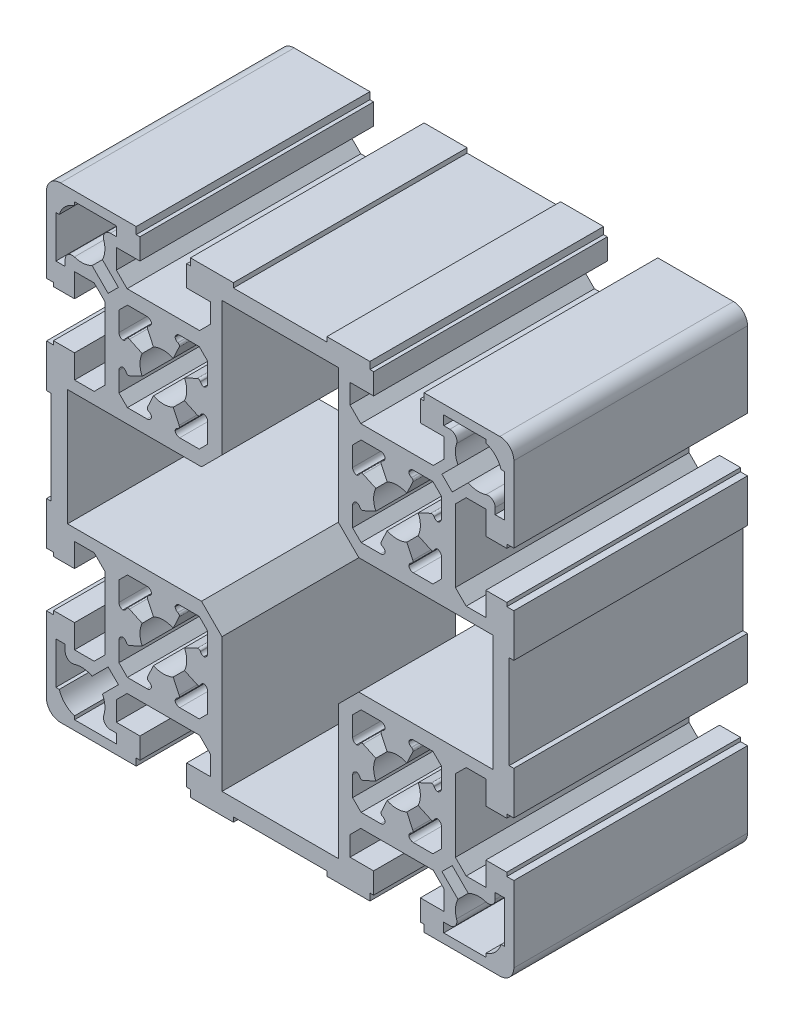
from build123d import *

# Parameters (mm, degrees)
BASE_EXTRUDE_DEPTH = 50


with BuildPart() as part:
    # Sketch1 → Base-Extrude (new body)
    with BuildSketch(Plane.XY):
        with BuildLine():
            Line((-17.25, -37.5), (-14.95, -39.8))
            Line((-14.95, -39.8), (-14.95, -44))
            Line((-14.95, -44), (-20, -44))
            Line((-20, -44), (-20, -48.5))
            Line((-20, -48.5), (-19.2, -48.5))
            Line((-19.2, -48.5), (-19.2, -50))
            Line((-19.2, -50), (-10, -50))
            Line((-10, -50), (-10, -49))
            Line((-10, -49), (10, -49))
            Line((10, -49), (10, -50))
            Line((10, -50), (19.2, -50))
            Line((19.2, -50), (19.2, -48.5))
            Line((19.2, -48.5), (20, -48.5))
            Line((20, -48.5), (20, -44))
            Line((20, -44), (14.95, -44))
            Line((14.95, -44), (14.95, -39.8))
            Line((14.95, -39.8), (17.25, -37.5))
            Line((17.25, -37.5), (32.75, -37.5))
            Line((32.75, -37.5), (35.05, -39.8))
            Line((35.05, -39.8), (35.05, -44))
            Line((35.05, -44), (30, -44))
            Line((30, -44), (30, -48.5))
            Line((30, -48.5), (30.8, -48.5))
            Line((30.8, -48.5), (30.8, -50))
            Line((30.8, -50), (47, -50))
            ThreePointArc((47, -50), (49.121320344, -49.121320344), (50, -47))
            Line((50, -47), (50, -30.8))
            Line((50, -30.8), (48.5, -30.8))
            Line((48.5, -30.8), (48.5, -30))
            Line((48.5, -30), (44, -30))
            Line((44, -30), (44, -35.05))
            Line((44, -35.05), (39.8, -35.05))
            Line((39.8, -35.05), (37.5, -32.75))
            Line((37.5, -32.75), (37.5, -17.25))
            Line((37.5, -17.25), (39.8, -14.95))
            Line((39.8, -14.95), (44, -14.95))
            Line((44, -14.95), (44, -20))
            Line((44, -20), (48.5, -20))
            Line((48.5, -20), (48.5, -19.2))
            Line((48.5, -19.2), (50, -19.2))
            Line((50, -19.2), (50, -10))
            Line((50, -10), (49, -10))
            Line((49, -10), (49, 10))
            Line((49, 10), (50, 10))
            Line((50, 10), (50, 19.2))
            Line((50, 19.2), (48.5, 19.2))
            Line((48.5, 19.2), (48.5, 20))
            Line((48.5, 20), (44, 20))
            Line((44, 20), (44, 14.95))
            Line((44, 14.95), (39.8, 14.95))
            Line((39.8, 14.95), (37.5, 17.25))
            Line((37.5, 17.25), (37.5, 32.75))
            Line((37.5, 32.75), (39.8, 35.05))
            Line((39.8, 35.05), (44, 35.05))
            Line((44, 35.05), (44, 30))
            Line((44, 30), (48.5, 30))
            Line((48.5, 30), (48.5, 30.8))
            Line((48.5, 30.8), (50, 30.8))
            Line((50, 30.8), (50, 47))
            ThreePointArc((50, 47), (49.121320344, 49.121320344), (47, 50))
            Line((47, 50), (30.8, 50))
            Line((30.8, 50), (30.8, 48.5))
            Line((30.8, 48.5), (30, 48.5))
            Line((30, 48.5), (30, 44))
            Line((30, 44), (35.05, 44))
            Line((35.05, 44), (35.05, 39.8))
            Line((35.05, 39.8), (32.75, 37.5))
            Line((32.75, 37.5), (17.25, 37.5))
            Line((17.25, 37.5), (14.95, 39.8))
            Line((14.95, 39.8), (14.95, 44))
            Line((14.95, 44), (20, 44))
            Line((20, 44), (20, 48.5))
            Line((20, 48.5), (19.2, 48.5))
            Line((19.2, 48.5), (19.2, 50))
            Line((19.2, 50), (10, 50))
            Line((10, 50), (10, 49))
            Line((10, 49), (-10, 49))
            Line((-10, 49), (-10, 50))
            Line((-10, 50), (-19.2, 50))
            Line((-19.2, 50), (-19.2, 48.5))
            Line((-19.2, 48.5), (-20, 48.5))
            Line((-20, 48.5), (-20, 44))
            Line((-20, 44), (-14.95, 44))
            Line((-14.95, 44), (-14.95, 39.8))
            Line((-14.95, 39.8), (-17.25, 37.5))
            Line((-17.25, 37.5), (-32.75, 37.5))
            Line((-32.75, 37.5), (-35.05, 39.8))
            Line((-35.05, 39.8), (-35.05, 44))
            Line((-35.05, 44), (-30, 44))
            Line((-30, 44), (-30, 48.5))
            Line((-30, 48.5), (-30.8, 48.5))
            Line((-30.8, 48.5), (-30.8, 50))
            Line((-30.8, 50), (-47, 50))
            ThreePointArc((-47, 50), (-49.121320344, 49.121320344), (-50, 47))
            Line((-50, 47), (-50, 30.8))
            Line((-50, 30.8), (-48.5, 30.8))
            Line((-48.5, 30.8), (-48.5, 30))
            Line((-48.5, 30), (-44, 30))
            Line((-44, 30), (-44, 35.05))
            Line((-44, 35.05), (-39.8, 35.05))
            Line((-39.8, 35.05), (-37.5, 32.75))
            Line((-37.5, 32.75), (-37.5, 17.25))
            Line((-37.5, 17.25), (-39.8, 14.95))
            Line((-39.8, 14.95), (-44, 14.95))
            Line((-44, 14.95), (-44, 20))
            Line((-44, 20), (-48.5, 20))
            Line((-48.5, 20), (-48.5, 19.2))
            Line((-48.5, 19.2), (-50, 19.2))
            Line((-50, 19.2), (-50, 10))
            Line((-50, 10), (-49, 10))
            Line((-49, 10), (-49, -10))
            Line((-49, -10), (-50, -10))
            Line((-50, -10), (-50, -19.2))
            Line((-50, -19.2), (-48.5, -19.2))
            Line((-48.5, -19.2), (-48.5, -20))
            Line((-48.5, -20), (-44, -20))
            Line((-44, -20), (-44, -14.95))
            Line((-44, -14.95), (-39.8, -14.95))
            Line((-39.8, -14.95), (-37.5, -17.25))
            Line((-37.5, -17.25), (-37.5, -32.75))
            Line((-37.5, -32.75), (-39.8, -35.05))
            Line((-39.8, -35.05), (-44, -35.05))
            Line((-44, -35.05), (-44, -30))
            Line((-44, -30), (-48.5, -30))
            Line((-48.5, -30), (-48.5, -30.8))
            Line((-48.5, -30.8), (-50, -30.8))
            Line((-50, -30.8), (-50, -47))
            ThreePointArc((-50, -47), (-49.121320344, -49.121320344), (-47, -50))
            Line((-47, -50), (-30.8, -50))
            Line((-30.8, -50), (-30.8, -48.5))
            Line((-30.8, -48.5), (-30, -48.5))
            Line((-30, -48.5), (-30, -44))
            Line((-30, -44), (-35.05, -44))
            Line((-35.05, -44), (-35.05, -39.8))
            Line((-35.05, -39.8), (-32.75, -37.5))
            Line((-32.75, -37.5), (-17.25, -37.5))
        make_face()
        with BuildLine():
            Line((-15.501428488, -32.680320318), (-17.320519374, -34.499411204))
            Line((-17.320519374, -34.499411204), (-21.501428488, -34.499411204))
            ThreePointArc((-21.501428488, -34.499411204), (-22.143687504, -34.265898879), (-22.485995728, -33.674417917))
            ThreePointArc((-22.485995728, -33.674417917), (-22.294361697, -33.240116066), (-21.92404675, -32.943116843))
            Line((-21.92404675, -32.943116843), (-21.862327157, -32.914336524))
            ThreePointArc((-21.862327157, -32.914336524), (-21.603789977, -32.632192702), (-21.620482394, -32.2498735))
            Line((-21.620482394, -32.2498735), (-22.888337179, -29.530950139))
            ThreePointArc((-22.888337179, -29.530950139), (-25.001428488, -29.999411204), (-27.114519797, -29.530950139))
            Line((-27.114519797, -29.530950139), (-28.382374582, -32.2498735))
            ThreePointArc((-28.382374582, -32.2498735), (-28.399066999, -32.632192702), (-28.140529819, -32.914336524))
            Line((-28.140529819, -32.914336524), (-28.078810226, -32.943116843))
            ThreePointArc((-28.078810226, -32.943116843), (-27.708495279, -33.240116066), (-27.516861248, -33.674417917))
            ThreePointArc((-27.516861248, -33.674417917), (-27.859169472, -34.265898879), (-28.501428488, -34.499411204))
            Line((-28.501428488, -34.499411204), (-32.682337602, -34.499411204))
            Line((-32.682337602, -34.499411204), (-34.501428488, -32.680320318))
            Line((-34.501428488, -32.680320318), (-34.501428488, -28.499411204))
            ThreePointArc((-34.501428488, -28.499411204), (-34.267916164, -27.857152188), (-33.676435201, -27.514843963))
            ThreePointArc((-33.676435201, -27.514843963), (-33.242133351, -27.706477994), (-32.945134128, -28.076792942))
            Line((-32.945134128, -28.076792942), (-32.916353809, -28.138512535))
            ThreePointArc((-32.916353809, -28.138512535), (-32.634209987, -28.397049714), (-32.251890784, -28.380357297))
            Line((-32.251890784, -28.380357297), (-29.532967423, -27.112502512))
            ThreePointArc((-29.532967423, -27.112502512), (-30.001428488, -24.999411204), (-29.532967423, -22.886319895))
            Line((-29.532967423, -22.886319895), (-32.251890784, -21.61846511))
            ThreePointArc((-32.251890784, -21.61846511), (-32.634209987, -21.601772693), (-32.916353809, -21.860309872))
            Line((-32.916353809, -21.860309872), (-32.94370564, -21.922618262))
            ThreePointArc((-32.94370564, -21.922618262), (-33.240704863, -22.292933209), (-33.675006713, -22.48456724))
            ThreePointArc((-33.675006713, -22.48456724), (-34.266487675, -22.142259016), (-34.5, -21.5))
            Line((-34.5, -21.5), (-34.5, -17.319090886))
            Line((-34.5, -17.319090886), (-32.680909114, -15.5))
            Line((-32.680909114, -15.5), (-28.5, -15.5))
            ThreePointArc((-28.5, -15.5), (-27.857740984, -15.733512325), (-27.51543276, -16.324993287))
            ThreePointArc((-27.51543276, -16.324993287), (-27.707066791, -16.759295137), (-28.077381738, -17.05629436))
            Line((-28.077381738, -17.05629436), (-28.139101331, -17.085074679))
            ThreePointArc((-28.139101331, -17.085074679), (-28.397638511, -17.367218501), (-28.380946094, -17.749537704))
            Line((-28.380946094, -17.749537704), (-27.113571921, -20.467430387))
            ThreePointArc((-27.113571921, -20.467430387), (-25.000905581, -19.999411231), (-22.888337179, -20.467872268))
            Line((-22.888337179, -20.467872268), (-21.620482394, -17.748948907))
            ThreePointArc((-21.620482394, -17.748948907), (-21.603789977, -17.366629705), (-21.862327157, -17.084485883))
            Line((-21.862327157, -17.084485883), (-21.92404675, -17.055705564))
            ThreePointArc((-21.92404675, -17.055705564), (-22.294361697, -16.758706341), (-22.485995728, -16.32440449))
            ThreePointArc((-22.485995728, -16.32440449), (-22.143687504, -15.732923528), (-21.501428488, -15.499411204))
            Line((-21.501428488, -15.499411204), (-17.320519374, -15.499411204))
            Line((-17.320519374, -15.499411204), (-15.501428488, -17.318502089))
            Line((-15.501428488, -17.318502089), (-15.501428488, -21.499411204))
            ThreePointArc((-15.501428488, -21.499411204), (-15.734940813, -22.141670219), (-16.326421775, -22.483978444))
            ThreePointArc((-16.326421775, -22.483978444), (-16.760723625, -22.292344413), (-17.057722849, -21.922029465))
            Line((-17.057722849, -21.922029465), (-17.086503167, -21.860309872))
            ThreePointArc((-17.086503167, -21.860309872), (-17.368646989, -21.601772693), (-17.750966192, -21.61846511))
            Line((-17.750966192, -21.61846511), (-20.469889553, -22.886319895))
            ThreePointArc((-20.469889553, -22.886319895), (-20.001428488, -24.999411204), (-20.469889553, -27.112502512))
            Line((-20.469889553, -27.112502512), (-17.750966192, -28.380357297))
            ThreePointArc((-17.750966192, -28.380357297), (-17.368646989, -28.397049714), (-17.086503167, -28.138512535))
            Line((-17.086503167, -28.138512535), (-17.057722849, -28.076792942))
            ThreePointArc((-17.057722849, -28.076792942), (-16.760723625, -27.706477994), (-16.326421775, -27.514843963))
            ThreePointArc((-16.326421775, -27.514843963), (-15.734940813, -27.857152188), (-15.501428488, -28.499411204))
            Line((-15.501428488, -28.499411204), (-15.501428488, -32.680320318))
        make_face(mode=Mode.SUBTRACT)
        Polygon((-12.45, -16.83355698), (-16.83355698, -12.45), (-45.5, -12.45), (-45.5, 12.45), (-16.83355698, 12.45), (-12.45, 16.83355698), (-12.45, 45.5), (12.45, 45.5), (12.45, 16.83355698), (16.83355698, 12.45), (45.5, 12.45), (45.5, -12.45), (16.83355698, -12.45), (12.45, -16.83355698), (12.45, -45.5), (-12.45, -45.5), align=None, mode=Mode.SUBTRACT)
        with BuildLine():
            Line((-48, -44), (-48, -35))
            Line((-48, -35), (-46, -35))
            Line((-46, -35), (-46, -36.315341562))
            ThreePointArc((-46, -36.315341562), (-45.382522608, -37.528252872), (-44.038461538, -37.742570432))
            ThreePointArc((-44.038461538, -37.742570432), (-42.111403126, -37.515123625), (-40.242871851, -38.038456263))
            Line((-40.242871851, -38.038456263), (-36.813982694, -34.609567107))
            Line((-36.813982694, -34.609567107), (-34.609567107, -36.813982694))
            Line((-34.609567107, -36.813982694), (-38.038456263, -40.242871851))
            ThreePointArc((-38.038456263, -40.242871851), (-37.515123625, -42.111403126), (-37.742570432, -44.038461538))
            ThreePointArc((-37.742570432, -44.038461538), (-37.528252872, -45.382522608), (-36.315341562, -46))
            Line((-36.315341562, -46), (-35, -46))
            Line((-35, -46), (-35, -48))
            Line((-35, -48), (-44, -48))
            Line((-44, -48), (-44, -47.269696007))
            ThreePointArc((-44, -47.269696007), (-46.035533906, -46.035533906), (-47.269696007, -44))
            Line((-47.269696007, -44), (-48, -44))
        make_face(mode=Mode.SUBTRACT)
        with BuildLine():
            Line((48, -35), (48, -44))
            Line((48, -44), (47.269696007, -44))
            ThreePointArc((47.269696007, -44), (46.035533906, -46.035533906), (44, -47.269696007))
            Line((44, -47.269696007), (44, -48))
            Line((44, -48), (35, -48))
            Line((35, -48), (35, -46))
            Line((35, -46), (36.315341562, -46))
            ThreePointArc((36.315341562, -46), (37.528252872, -45.382522608), (37.742570432, -44.038461538))
            ThreePointArc((37.742570432, -44.038461538), (37.515123625, -42.111403126), (38.038456263, -40.242871851))
            Line((38.038456263, -40.242871851), (34.609567107, -36.813982694))
            Line((34.609567107, -36.813982694), (36.813982694, -34.609567107))
            Line((36.813982694, -34.609567107), (40.242871851, -38.038456263))
            ThreePointArc((40.242871851, -38.038456263), (42.111403126, -37.515123625), (44.038461538, -37.742570432))
            ThreePointArc((44.038461538, -37.742570432), (45.382522608, -37.528252872), (46, -36.315341562))
            Line((46, -36.315341562), (46, -35))
            Line((46, -35), (48, -35))
        make_face(mode=Mode.SUBTRACT)
        with BuildLine():
            Line((34.5, -17.319090886), (34.5, -21.5))
            ThreePointArc((34.5, -21.5), (34.266487675, -22.142259016), (33.675006713, -22.48456724))
            ThreePointArc((33.675006713, -22.48456724), (33.240704863, -22.292933209), (32.94370564, -21.922618262))
            Line((32.94370564, -21.922618262), (32.914925321, -21.860898669))
            ThreePointArc((32.914925321, -21.860898669), (32.632781499, -21.602361489), (32.250462296, -21.619053906))
            Line((32.250462296, -21.619053906), (29.531538935, -22.886908691))
            ThreePointArc((29.531538935, -22.886908691), (30, -25), (29.531538935, -27.113091309))
            Line((29.531538935, -27.113091309), (32.250462296, -28.380946094))
            ThreePointArc((32.250462296, -28.380946094), (32.632781499, -28.397638511), (32.914925321, -28.139101331))
            Line((32.914925321, -28.139101331), (32.94370564, -28.077381738))
            ThreePointArc((32.94370564, -28.077381738), (33.240704863, -27.707066791), (33.675006713, -27.51543276))
            ThreePointArc((33.675006713, -27.51543276), (34.266487675, -27.857740984), (34.5, -28.5))
            Line((34.5, -28.5), (34.5, -32.680909114))
            Line((34.5, -32.680909114), (32.680909114, -34.5))
            Line((32.680909114, -34.5), (28.5, -34.5))
            ThreePointArc((28.5, -34.5), (27.857740984, -34.266487675), (27.51543276, -33.675006713))
            ThreePointArc((27.51543276, -33.675006713), (27.707066791, -33.240704863), (28.077381738, -32.94370564))
            Line((28.077381738, -32.94370564), (28.139101331, -32.914925321))
            ThreePointArc((28.139101331, -32.914925321), (28.397638511, -32.632781499), (28.380946094, -32.250462296))
            Line((28.380946094, -32.250462296), (27.113091309, -29.531538935))
            ThreePointArc((27.113091309, -29.531538935), (25, -30), (22.886908691, -29.531538935))
            Line((22.886908691, -29.531538935), (21.619053906, -32.250462296))
            ThreePointArc((21.619053906, -32.250462296), (21.602361489, -32.632781499), (21.860898669, -32.914925321))
            Line((21.860898669, -32.914925321), (21.922618262, -32.94370564))
            ThreePointArc((21.922618262, -32.94370564), (22.292933209, -33.240704863), (22.48456724, -33.675006713))
            ThreePointArc((22.48456724, -33.675006713), (22.142259016, -34.266487675), (21.5, -34.5))
            Line((21.5, -34.5), (17.319090886, -34.5))
            Line((17.319090886, -34.5), (15.5, -32.680909114))
            Line((15.5, -32.680909114), (15.5, -28.5))
            ThreePointArc((15.5, -28.5), (15.733512325, -27.857740984), (16.324993287, -27.51543276))
            ThreePointArc((16.324993287, -27.51543276), (16.759295137, -27.707066791), (17.05629436, -28.077381738))
            Line((17.05629436, -28.077381738), (17.085074679, -28.139101331))
            ThreePointArc((17.085074679, -28.139101331), (17.367218501, -28.397638511), (17.749537704, -28.380946094))
            Line((17.749537704, -28.380946094), (20.468461065, -27.113091309))
            ThreePointArc((20.468461065, -27.113091309), (20, -25), (20.468461065, -22.886908691))
            Line((20.468461065, -22.886908691), (17.749537704, -21.619053906))
            ThreePointArc((17.749537704, -21.619053906), (17.367218501, -21.602361489), (17.085074679, -21.860898669))
            Line((17.085074679, -21.860898669), (17.05629436, -21.922618262))
            ThreePointArc((17.05629436, -21.922618262), (16.759295137, -22.292933209), (16.324993287, -22.48456724))
            ThreePointArc((16.324993287, -22.48456724), (15.733512325, -22.142259016), (15.5, -21.5))
            Line((15.5, -21.5), (15.5, -17.319090886))
            Line((15.5, -17.319090886), (17.319090886, -15.5))
            Line((17.319090886, -15.5), (21.5, -15.5))
            ThreePointArc((21.5, -15.5), (22.142259016, -15.733512325), (22.48456724, -16.324993287))
            ThreePointArc((22.48456724, -16.324993287), (22.292933209, -16.759295137), (21.922618262, -17.05629436))
            Line((21.922618262, -17.05629436), (21.860898669, -17.085074679))
            ThreePointArc((21.860898669, -17.085074679), (21.602361489, -17.367218501), (21.619053906, -17.749537704))
            Line((21.619053906, -17.749537704), (22.886908691, -20.468461065))
            ThreePointArc((22.886908691, -20.468461065), (25, -20), (27.113091309, -20.468461065))
            Line((27.113091309, -20.468461065), (28.380946094, -17.749537704))
            ThreePointArc((28.380946094, -17.749537704), (28.397638511, -17.367218501), (28.139101331, -17.085074679))
            Line((28.139101331, -17.085074679), (28.077381738, -17.05629436))
            ThreePointArc((28.077381738, -17.05629436), (27.707066791, -16.759295137), (27.51543276, -16.324993287))
            ThreePointArc((27.51543276, -16.324993287), (27.857740984, -15.733512325), (28.5, -15.5))
            Line((28.5, -15.5), (32.680909114, -15.5))
            Line((32.680909114, -15.5), (34.5, -17.319090886))
        make_face(mode=Mode.SUBTRACT)
        with BuildLine():
            Line((-17.319090886, 34.5), (-15.5, 32.680909114))
            Line((-15.5, 32.680909114), (-15.5, 28.5))
            ThreePointArc((-15.5, 28.5), (-15.733512325, 27.857740984), (-16.324993287, 27.51543276))
            ThreePointArc((-16.324993287, 27.51543276), (-16.759295137, 27.707066791), (-17.05629436, 28.077381738))
            Line((-17.05629436, 28.077381738), (-17.085074679, 28.139101331))
            ThreePointArc((-17.085074679, 28.139101331), (-17.367218501, 28.397638511), (-17.749537704, 28.380946094))
            Line((-17.749537704, 28.380946094), (-20.468461065, 27.113091309))
            ThreePointArc((-20.468461065, 27.113091309), (-20, 25), (-20.468461065, 22.886908691))
            Line((-20.468461065, 22.886908691), (-17.749537704, 21.619053906))
            ThreePointArc((-17.749537704, 21.619053906), (-17.367218501, 21.602361489), (-17.085074679, 21.860898669))
            Line((-17.085074679, 21.860898669), (-17.05629436, 21.922618262))
            ThreePointArc((-17.05629436, 21.922618262), (-16.759295137, 22.292933209), (-16.324993287, 22.48456724))
            ThreePointArc((-16.324993287, 22.48456724), (-15.733512325, 22.142259016), (-15.5, 21.5))
            Line((-15.5, 21.5), (-15.5, 17.319090886))
            Line((-15.5, 17.319090886), (-17.319090886, 15.5))
            Line((-17.319090886, 15.5), (-21.5, 15.5))
            ThreePointArc((-21.5, 15.5), (-22.142259016, 15.733512325), (-22.48456724, 16.324993287))
            ThreePointArc((-22.48456724, 16.324993287), (-22.292933209, 16.759295137), (-21.922618262, 17.05629436))
            Line((-21.922618262, 17.05629436), (-21.860898669, 17.085074679))
            ThreePointArc((-21.860898669, 17.085074679), (-21.602361489, 17.367218501), (-21.619053906, 17.749537704))
            Line((-21.619053906, 17.749537704), (-22.886908691, 20.468461065))
            ThreePointArc((-22.886908691, 20.468461065), (-25, 20), (-27.113091309, 20.468461065))
            Line((-27.113091309, 20.468461065), (-28.380946094, 17.749537704))
            ThreePointArc((-28.380946094, 17.749537704), (-28.397638511, 17.367218501), (-28.139101331, 17.085074679))
            Line((-28.139101331, 17.085074679), (-28.077381738, 17.05629436))
            ThreePointArc((-28.077381738, 17.05629436), (-27.707066791, 16.759295137), (-27.51543276, 16.324993287))
            ThreePointArc((-27.51543276, 16.324993287), (-27.857740984, 15.733512325), (-28.5, 15.5))
            Line((-28.5, 15.5), (-32.680909114, 15.5))
            Line((-32.680909114, 15.5), (-34.5, 17.319090886))
            Line((-34.5, 17.319090886), (-34.5, 21.5))
            ThreePointArc((-34.5, 21.5), (-34.266487675, 22.142259016), (-33.675006713, 22.48456724))
            ThreePointArc((-33.675006713, 22.48456724), (-33.240704863, 22.292933209), (-32.94370564, 21.922618262))
            Line((-32.94370564, 21.922618262), (-32.914925321, 21.860898669))
            ThreePointArc((-32.914925321, 21.860898669), (-32.632781499, 21.602361489), (-32.250462296, 21.619053906))
            Line((-32.250462296, 21.619053906), (-29.531538935, 22.886908691))
            ThreePointArc((-29.531538935, 22.886908691), (-30, 25), (-29.531538935, 27.113091309))
            Line((-29.531538935, 27.113091309), (-32.250462296, 28.380946094))
            ThreePointArc((-32.250462296, 28.380946094), (-32.632781499, 28.397638511), (-32.914925321, 28.139101331))
            Line((-32.914925321, 28.139101331), (-32.94370564, 28.077381738))
            ThreePointArc((-32.94370564, 28.077381738), (-33.240704863, 27.707066791), (-33.675006713, 27.51543276))
            ThreePointArc((-33.675006713, 27.51543276), (-34.266487675, 27.857740984), (-34.5, 28.5))
            Line((-34.5, 28.5), (-34.5, 32.680909114))
            Line((-34.5, 32.680909114), (-32.680909114, 34.5))
            Line((-32.680909114, 34.5), (-28.5, 34.5))
            ThreePointArc((-28.5, 34.5), (-27.857740984, 34.266487675), (-27.51543276, 33.675006713))
            ThreePointArc((-27.51543276, 33.675006713), (-27.707066791, 33.240704863), (-28.077381738, 32.94370564))
            Line((-28.077381738, 32.94370564), (-28.139690128, 32.916353809))
            ThreePointArc((-28.139690128, 32.916353809), (-28.398227307, 32.634209987), (-28.38153489, 32.251890784))
            Line((-28.38153489, 32.251890784), (-27.1130278, 29.531568549))
            ThreePointArc((-27.1130278, 29.531568549), (-24.999964963, 30), (-22.886908691, 29.531538935))
            Line((-22.886908691, 29.531538935), (-21.619053906, 32.250462296))
            ThreePointArc((-21.619053906, 32.250462296), (-21.602361489, 32.632781499), (-21.860898669, 32.914925321))
            Line((-21.860898669, 32.914925321), (-21.922618262, 32.94370564))
            ThreePointArc((-21.922618262, 32.94370564), (-22.292933209, 33.240704863), (-22.48456724, 33.675006713))
            ThreePointArc((-22.48456724, 33.675006713), (-22.142259016, 34.266487675), (-21.5, 34.5))
            Line((-21.5, 34.5), (-17.319090886, 34.5))
        make_face(mode=Mode.SUBTRACT)
        with BuildLine():
            Line((-48, 35), (-48, 44))
            Line((-48, 44), (-47.269696007, 44))
            ThreePointArc((-47.269696007, 44), (-46.035533906, 46.035533906), (-44, 47.269696007))
            Line((-44, 47.269696007), (-44, 48))
            Line((-44, 48), (-35, 48))
            Line((-35, 48), (-35, 46))
            Line((-35, 46), (-36.315341562, 46))
            ThreePointArc((-36.315341562, 46), (-37.528252872, 45.382522608), (-37.742570432, 44.038461538))
            ThreePointArc((-37.742570432, 44.038461538), (-37.515123625, 42.111403126), (-38.038456263, 40.242871851))
            Line((-38.038456263, 40.242871851), (-34.609567107, 36.813982694))
            Line((-34.609567107, 36.813982694), (-36.813982694, 34.609567107))
            Line((-36.813982694, 34.609567107), (-40.242871851, 38.038456263))
            ThreePointArc((-40.242871851, 38.038456263), (-42.111403126, 37.515123625), (-44.038461538, 37.742570432))
            ThreePointArc((-44.038461538, 37.742570432), (-45.382522608, 37.528252872), (-46, 36.315341562))
            Line((-46, 36.315341562), (-46, 35))
            Line((-46, 35), (-48, 35))
        make_face(mode=Mode.SUBTRACT)
        with BuildLine():
            Line((28.380946094, 17.749537704), (27.113091309, 20.468461065))
            ThreePointArc((27.113091309, 20.468461065), (25, 20), (22.886908691, 20.468461065))
            Line((22.886908691, 20.468461065), (21.619053906, 17.749537704))
            ThreePointArc((21.619053906, 17.749537704), (21.602361489, 17.367218501), (21.860898669, 17.085074679))
            Line((21.860898669, 17.085074679), (21.922618262, 17.05629436))
            ThreePointArc((21.922618262, 17.05629436), (22.292933209, 16.759295137), (22.48456724, 16.324993287))
            ThreePointArc((22.48456724, 16.324993287), (22.142259016, 15.733512325), (21.5, 15.5))
            Line((21.5, 15.5), (17.319090886, 15.5))
            Line((17.319090886, 15.5), (15.5, 17.319090886))
            Line((15.5, 17.319090886), (15.5, 21.5))
            ThreePointArc((15.5, 21.5), (15.733512325, 22.142259016), (16.324993287, 22.48456724))
            ThreePointArc((16.324993287, 22.48456724), (16.759295137, 22.292933209), (17.05629436, 21.922618262))
            Line((17.05629436, 21.922618262), (17.085074679, 21.860898669))
            ThreePointArc((17.085074679, 21.860898669), (17.367218501, 21.602361489), (17.749537704, 21.619053906))
            Line((17.749537704, 21.619053906), (20.468461065, 22.886908691))
            ThreePointArc((20.468461065, 22.886908691), (20, 25), (20.468461065, 27.113091309))
            Line((20.468461065, 27.113091309), (17.749537704, 28.380946094))
            ThreePointArc((17.749537704, 28.380946094), (17.367218501, 28.397638511), (17.085074679, 28.139101331))
            Line((17.085074679, 28.139101331), (17.05629436, 28.077381738))
            ThreePointArc((17.05629436, 28.077381738), (16.759295137, 27.707066791), (16.324993287, 27.51543276))
            ThreePointArc((16.324993287, 27.51543276), (15.733512325, 27.857740984), (15.5, 28.5))
            Line((15.5, 28.5), (15.5, 32.680909114))
            Line((15.5, 32.680909114), (17.319090886, 34.5))
            Line((17.319090886, 34.5), (21.5, 34.5))
            ThreePointArc((21.5, 34.5), (22.142259016, 34.266487675), (22.48456724, 33.675006713))
            ThreePointArc((22.48456724, 33.675006713), (22.292933209, 33.240704863), (21.922618262, 32.94370564))
            Line((21.922618262, 32.94370564), (21.860309872, 32.916353809))
            ThreePointArc((21.860309872, 32.916353809), (21.601772693, 32.634209987), (21.61846511, 32.251890784))
            Line((21.61846511, 32.251890784), (22.8869722, 29.531568549))
            ThreePointArc((22.8869722, 29.531568549), (25.000035037, 30), (27.113091309, 29.531538935))
            Line((27.113091309, 29.531538935), (28.380946094, 32.250462296))
            ThreePointArc((28.380946094, 32.250462296), (28.397638511, 32.632781499), (28.139101331, 32.914925321))
            Line((28.139101331, 32.914925321), (28.076792942, 32.942277151))
            ThreePointArc((28.076792942, 32.942277151), (27.706477994, 33.239276375), (27.514843963, 33.673578225))
            ThreePointArc((27.514843963, 33.673578225), (27.857152188, 34.265059187), (28.499411203, 34.498571512))
            Line((28.499411203, 34.498571512), (32.680320318, 34.498571512))
            Line((32.680320318, 34.498571512), (34.499411203, 32.679480626))
            Line((34.499411203, 32.679480626), (34.499411203, 28.498571512))
            ThreePointArc((34.499411203, 28.498571512), (34.265898879, 27.856312496), (33.674417917, 27.514004272))
            ThreePointArc((33.674417917, 27.514004272), (33.240116066, 27.705638303), (32.943116843, 28.07595325))
            Line((32.943116843, 28.07595325), (32.914336524, 28.137672843))
            ThreePointArc((32.914336524, 28.137672843), (32.632192702, 28.396210023), (32.2498735, 28.379517606))
            Line((32.2498735, 28.379517606), (29.531980816, 27.112143433))
            ThreePointArc((29.531980816, 27.112143433), (29.999999973, 24.999477093), (29.531538935, 22.886908691))
            Line((29.531538935, 22.886908691), (32.250462296, 21.619053906))
            ThreePointArc((32.250462296, 21.619053906), (32.632781499, 21.602361489), (32.914925321, 21.860898669))
            Line((32.914925321, 21.860898669), (32.94370564, 21.922618262))
            ThreePointArc((32.94370564, 21.922618262), (33.240704863, 22.292933209), (33.675006713, 22.48456724))
            ThreePointArc((33.675006713, 22.48456724), (34.266487675, 22.142259016), (34.5, 21.5))
            Line((34.5, 21.5), (34.5, 17.319090886))
            Line((34.5, 17.319090886), (32.680909114, 15.5))
            Line((32.680909114, 15.5), (28.5, 15.5))
            ThreePointArc((28.5, 15.5), (27.857740984, 15.733512325), (27.51543276, 16.324993287))
            ThreePointArc((27.51543276, 16.324993287), (27.707066791, 16.759295137), (28.077381738, 17.05629436))
            Line((28.077381738, 17.05629436), (28.139101331, 17.085074679))
            ThreePointArc((28.139101331, 17.085074679), (28.397638511, 17.367218501), (28.380946094, 17.749537704))
        make_face(mode=Mode.SUBTRACT)
        with BuildLine():
            Line((48, 44), (48, 35))
            Line((48, 35), (46, 35))
            Line((46, 35), (46, 36.315341562))
            ThreePointArc((46, 36.315341562), (45.382522608, 37.528252872), (44.038461538, 37.742570432))
            ThreePointArc((44.038461538, 37.742570432), (42.111403126, 37.515123625), (40.242871851, 38.038456263))
            Line((40.242871851, 38.038456263), (36.813982694, 34.609567107))
            Line((36.813982694, 34.609567107), (34.609567107, 36.813982694))
            Line((34.609567107, 36.813982694), (38.038456263, 40.242871851))
            ThreePointArc((38.038456263, 40.242871851), (37.515123625, 42.111403126), (37.742570432, 44.038461538))
            ThreePointArc((37.742570432, 44.038461538), (37.528252872, 45.382522608), (36.315341562, 46))
            Line((36.315341562, 46), (35, 46))
            Line((35, 46), (35, 48))
            Line((35, 48), (44, 48))
            Line((44, 48), (44, 47.269696007))
            ThreePointArc((44, 47.269696007), (46.035533906, 46.035533906), (47.269696007, 44))
            Line((47.269696007, 44), (48, 44))
        make_face(mode=Mode.SUBTRACT)
    extrude(amount=-BASE_EXTRUDE_DEPTH)


solid = part.part
